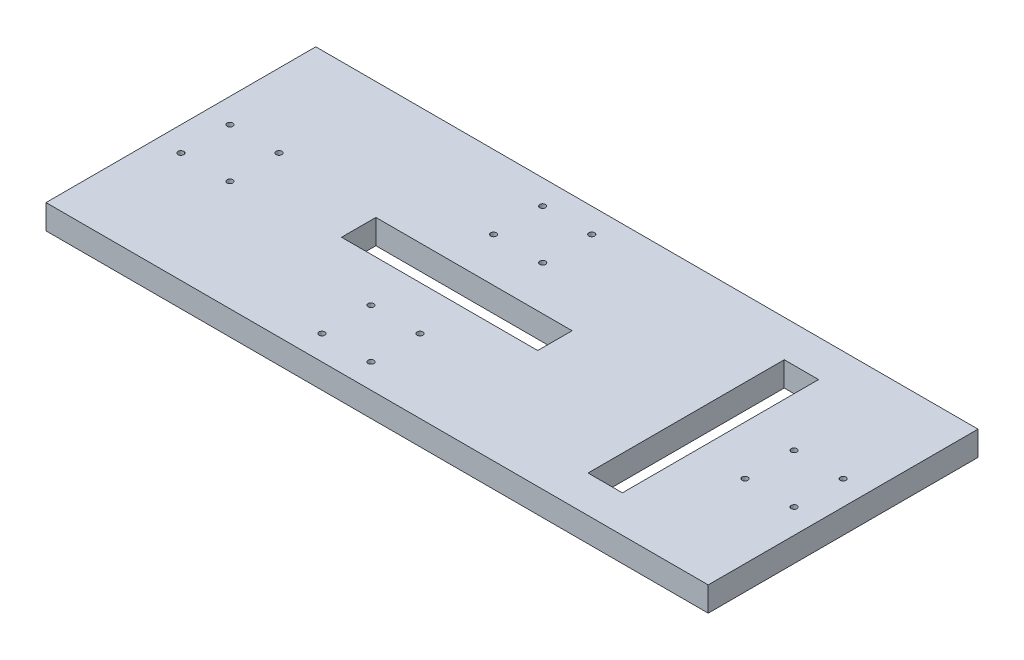
from build123d import *

# Parameters (mm, degrees)
SKETCH1_W           = 342.9
SKETCH1_H           = 139.7
BOSS_EXTRUDE1_DEPTH = 12.7
SKETCH3_R           = 1.5
SKETCH3_R_2         = 1.500000048
CUT_EXTRUDE1_DEPTH  = 13.7
SKETCH4_W           = 17.78
SKETCH4_H           = 101.6
SKETCH4_W_2         = 101.6
SKETCH4_H_2         = 17.78
CUT_EXTRUDE2_DEPTH  = 13.7
SKETCH5_R           = 1.5
CUT_EXTRUDE3_DEPTH  = 13.7


with BuildPart() as part:
    # Sketch1 → Boss-Extrude1 (new body)
    with BuildSketch(Plane(origin=(0, 0, 0), x_dir=(1, 0, 0), z_dir=(0, 1, 0))):
        with Locations((171.45, 69.85)):
            Rectangle(SKETCH1_W, SKETCH1_H)
    extrude(amount=BOSS_EXTRUDE1_DEPTH)

    # Sketch3 → Cut-Extrude1 (cut, through all)
    with BuildSketch(Plane(origin=(0, 12.7, 0), x_dir=(1, 0, 0), z_dir=(0, 1, 0))):
        with Locations((330.2, 82.55)):
            Circle(SKETCH3_R)
        with Locations((330.2, 57.15)):
            Circle(SKETCH3_R_2)
        with Locations((304.8, 57.15)):
            Circle(SKETCH3_R)
        with Locations((304.8, 82.55)):
            Circle(SKETCH3_R_2)
    cut_extrude1 = extrude(amount=-CUT_EXTRUDE1_DEPTH, mode=Mode.SUBTRACT)

    # Mirror1: Cut-Extrude1 across plane
    add(cut_extrude1.mirror(Plane.ZY.offset(-171.45)), mode=Mode.SUBTRACT)

    # Sketch4 → Cut-Extrude2 (cut, through all)
    with BuildSketch(Plane(origin=(0, 12.7, 0), x_dir=(1, 0, 0), z_dir=(0, 1, 0))):
        with Locations((270.51, 69.85)):
            Rectangle(SKETCH4_W, SKETCH4_H)
        with Locations((142.875, 69.85)):
            Rectangle(SKETCH4_W_2, SKETCH4_H_2)
    extrude(amount=-CUT_EXTRUDE2_DEPTH, mode=Mode.SUBTRACT)

    # Sketch5 → Cut-Extrude3 (cut, through all)
    with BuildSketch(Plane(origin=(0, 12.7, 0), x_dir=(1, 0, 0), z_dir=(0, 1, 0))):
        with Locations((130.175, 127)):
            Circle(SKETCH5_R)
        with Locations((155.575, 127)):
            Circle(SKETCH5_R)
        with Locations((155.575, 101.6)):
            Circle(SKETCH5_R)
        with Locations((130.175, 101.6)):
            Circle(SKETCH5_R)
    cut_extrude3 = extrude(amount=-CUT_EXTRUDE3_DEPTH, mode=Mode.SUBTRACT)

    # Mirror3: Cut-Extrude3 across plane
    add(cut_extrude3.mirror(Plane(origin=(0, 0, -69.85), x_dir=(1, 0, 0), z_dir=(0, 0, -1))), mode=Mode.SUBTRACT)


solid = part.part
